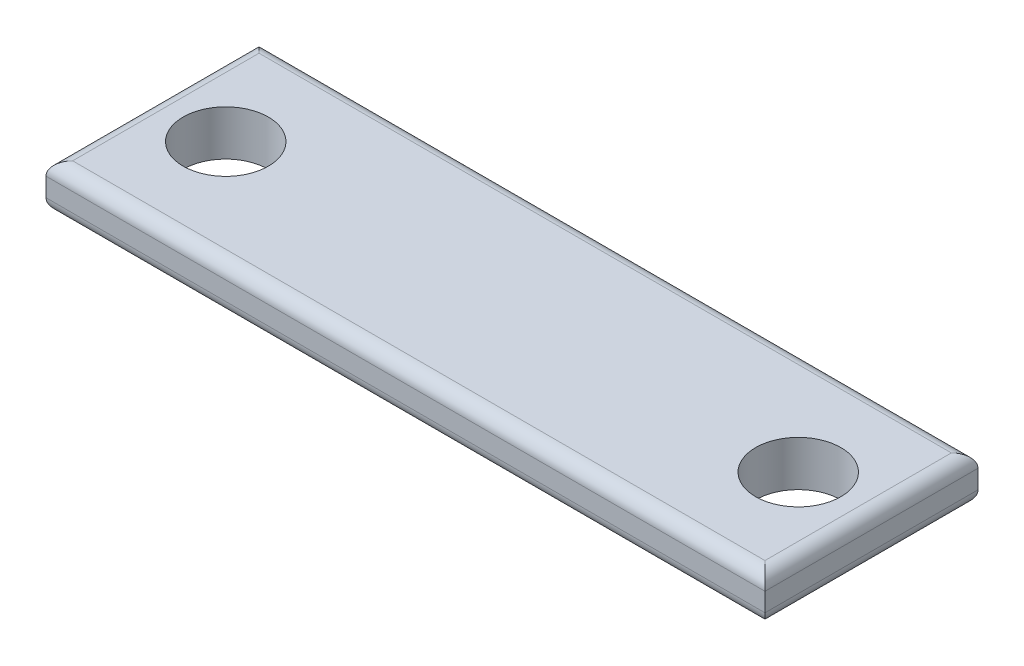
from build123d import *

# Parameters (mm, degrees)
SKETCH1_W           = 27
SKETCH1_H           = 8
SKETCH1_R           = 1.6
BOSS_EXTRUDE1_DEPTH = 1.7
FILLET1_R           = 0.5
FILLET2_R           = 0.5


with BuildPart() as part:
    # Sketch1 → Boss-Extrude1 (new body)
    with BuildSketch(Plane(origin=(0, 0, 0), x_dir=(1, 0, 0), z_dir=(0, 1, 0))):
        Rectangle(SKETCH1_W, SKETCH1_H)
        with Locations((-10.75, 0)):
            Circle(SKETCH1_R, mode=Mode.SUBTRACT)
        with Locations((10.75, 0)):
            Circle(SKETCH1_R, mode=Mode.SUBTRACT)
    extrude(amount=BOSS_EXTRUDE1_DEPTH)

    # Fillet1
    fillet1_edges = [part.edges().sort_by_distance(p)[0] for p in [
        (0, 0, -4),
        (13.5, 0, 0),
        (0, 0, 4),
        (-13.5, 0, 0),
    ]]
    fillet(fillet1_edges, radius=FILLET1_R)

    # Fillet2
    fillet2_edges = [part.edges().sort_by_distance(p)[0] for p in [
        (13.5, 1.7, 0),
        (0, 1.7, -4),
        (-13.5, 1.7, 0),
        (0, 1.7, 4),
    ]]
    fillet(fillet2_edges, radius=FILLET2_R)


solid = part.part
